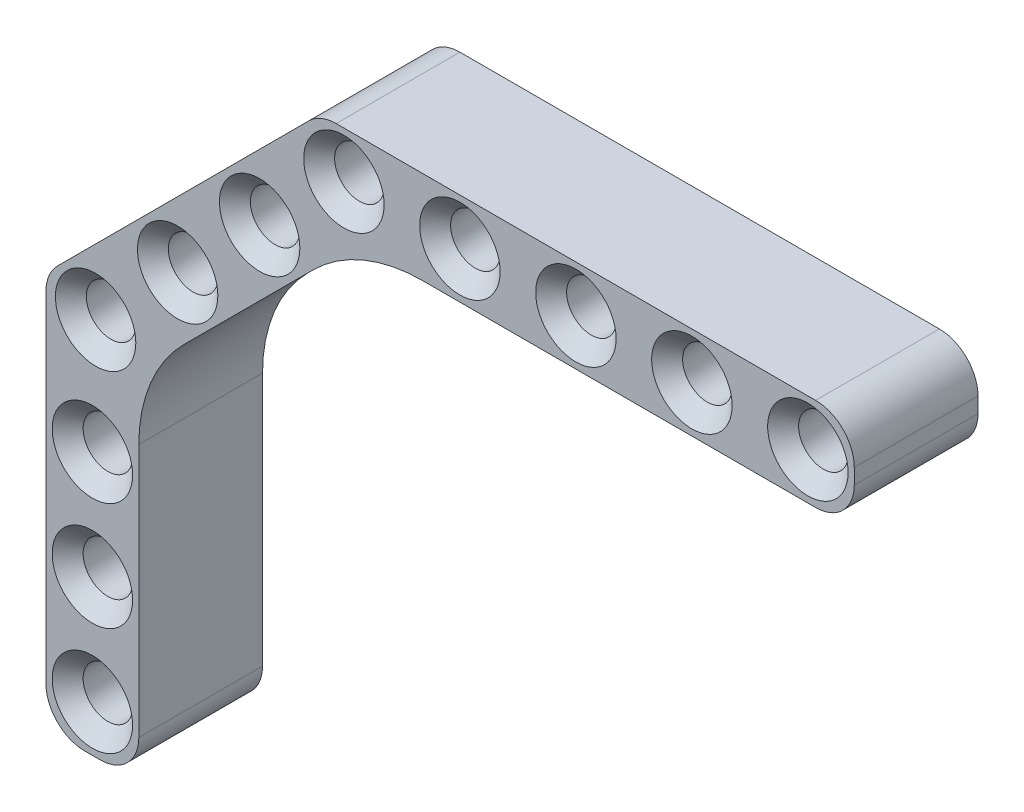
from build123d import *

# Parameters (mm, degrees)
SKETCH1_R           = 1.6
BOSS_EXTRUDE1_DEPTH = 8
CHAMFER1_SIZE       = 1
SKETCH2_R           = 1.6
BOSS_EXTRUDE3_DEPTH = 8
FILLET1_R           = 10
CHAMFER2_SIZE       = 1
SKETCH3_R           = 1.6
BOSS_EXTRUDE4_DEPTH = 8
CHAMFER5_SIZE       = 1
FILLET2_R           = 10


with BuildPart() as part:
    # Sketch1 → Boss-Extrude1 (new body)
    with BuildSketch(Plane.XY):
        with BuildLine():
            Line((-0.5, 3), (30.5, 3))
            ThreePointArc((30.5, 3), (32.267766953, 2.267766953), (33, 0.5))
            Line((33, 0.5), (33, -0.5))
            ThreePointArc((33, -0.5), (32.267766953, -2.267766953), (30.5, -3))
            Line((30.5, -3), (-0.5, -3))
            ThreePointArc((-0.5, -3), (-2.267766953, -2.267766953), (-3, -0.5))
            Line((-3, -0.5), (-3, 0.5))
            ThreePointArc((-3, 0.5), (-2.267766953, 2.267766953), (-0.5, 3))
        make_face()
        Circle(SKETCH1_R, mode=Mode.SUBTRACT)
        with Locations((7.5, 0)):
            Circle(SKETCH1_R, mode=Mode.SUBTRACT)
        with Locations((15, 0)):
            Circle(SKETCH1_R, mode=Mode.SUBTRACT)
        with Locations((22.5, 0)):
            Circle(SKETCH1_R, mode=Mode.SUBTRACT)
        with Locations((30, 0)):
            Circle(SKETCH1_R, mode=Mode.SUBTRACT)
    extrude(amount=BOSS_EXTRUDE1_DEPTH)

    # Chamfer1
    chamfer1_edges = [part.edges().sort_by_distance(p)[0] for p in [
        (-1.6, 0, 0),
        (-1.6, 0, 8),
        (5.9, 0, 0),
        (5.9, 0, 8),
        (13.4, 0, 0),
        (13.4, 0, 8),
        (20.9, 0, 0),
        (20.9, 0, 8),
        (28.4, 0, 0),
        (28.4, 0, 8),
    ]]
    chamfer(chamfer1_edges, length=CHAMFER1_SIZE)

    # Sketch2 → Boss-Extrude3 (add)
    with BuildSketch(Plane.XY.offset(8)):
        with BuildLine():
            ThreePointArc((-3, 0.5), (-2.809698831, 1.456708581), (-2.267766953, 2.267766953))
            Line((-2.267766953, 2.267766953), (-18.529200529, -13.993666623))
            ThreePointArc((-18.529200529, -13.993666623), (-19.261433576, -15.761433576), (-18.529200529, -17.529200529))
            Line((-18.529200529, -17.529200529), (-17.822093748, -18.23630731))
            ThreePointArc((-17.822093748, -18.23630731), (-16.054326795, -18.968540357), (-14.286559842, -18.23630731))
            Line((-14.286559842, -18.23630731), (0.949747468, -3))
            Line((0.949747468, -3), (-0.5, -3))
            ThreePointArc((-0.5, -3), (-2.267766953, -2.267766953), (-3, -0.5))
            Line((-3, -0.5), (-3, 0.5))
        make_face()
        with Locations((-16.054326795, -15.761433576)):
            Circle(SKETCH2_R, mode=Mode.SUBTRACT)
        with Locations((-10.751025936, -10.458132717)):
            Circle(SKETCH2_R, mode=Mode.SUBTRACT)
        with Locations((-5.447725077, -5.154831858)):
            Circle(SKETCH2_R, mode=Mode.SUBTRACT)
    extrude(amount=-BOSS_EXTRUDE3_DEPTH)

    # Fillet1
    fillet1_edges = [part.edges().sort_by_distance(p)[0] for p in [
        (0.949747468, -3, 4),
    ]]
    fillet(fillet1_edges, radius=FILLET1_R)

    # Chamfer2
    chamfer2_edges = [part.edges().sort_by_distance(p)[0] for p in [
        (-17.654326795, -15.761433576, 8),
        (-12.351025936, -10.458132717, 8),
        (-7.047725077, -5.154831858, 8),
        (-7.047725077, -5.154831858, 0),
        (-12.351025936, -10.458132717, 0),
        (-17.654326795, -15.761433576, 0),
    ]]
    chamfer(chamfer2_edges, length=CHAMFER2_SIZE)

    # Sketch3 → Boss-Extrude4 (add)
    with BuildSketch(Plane.XY.offset(8)):
        with BuildLine():
            ThreePointArc((-18.529200529, -17.529200529), (-19.071132407, -16.718142157), (-19.261433576, -15.761433576))
            Line((-19.261433576, -15.761433576), (-19.261433576, -37.761433576))
            ThreePointArc((-19.261433576, -37.761433576), (-18.529200529, -39.529200529), (-16.761433576, -40.261433576))
            Line((-16.761433576, -40.261433576), (-15.761433576, -40.261433576))
            ThreePointArc((-15.761433576, -40.261433576), (-13.993666623, -39.529200529), (-13.261433576, -37.761433576))
            Line((-13.261433576, -37.761433576), (-13.261433576, -17.211181044))
            Line((-13.261433576, -17.211181044), (-14.286559842, -18.23630731))
            ThreePointArc((-14.286559842, -18.23630731), (-16.054326795, -18.968540357), (-17.822093748, -18.23630731))
            Line((-17.822093748, -18.23630731), (-18.529200529, -17.529200529))
        make_face()
        with Locations((-16.261433576, -30.261433576)):
            Circle(SKETCH3_R, mode=Mode.SUBTRACT)
        with Locations((-16.261433576, -37.261433576)):
            Circle(SKETCH3_R, mode=Mode.SUBTRACT)
        with Locations((-16.261433576, -23.261433576)):
            Circle(SKETCH3_R, mode=Mode.SUBTRACT)
    extrude(amount=-BOSS_EXTRUDE4_DEPTH)

    # Chamfer5
    chamfer5_edges = [part.edges().sort_by_distance(p)[0] for p in [
        (-17.861433576, -37.261433576, 8),
        (-17.861433576, -30.261433576, 8),
        (-17.861433576, -23.261433576, 8),
        (-17.861433576, -23.261433576, 0),
        (-17.861433576, -30.261433576, 0),
        (-17.861433576, -37.261433576, 0),
    ]]
    chamfer(chamfer5_edges, length=CHAMFER5_SIZE)

    # Fillet2
    fillet2_edges = [part.edges().sort_by_distance(p)[0] for p in [
        (-13.261433576, -17.211181044, 4),
    ]]
    fillet(fillet2_edges, radius=FILLET2_R)


solid = part.part
